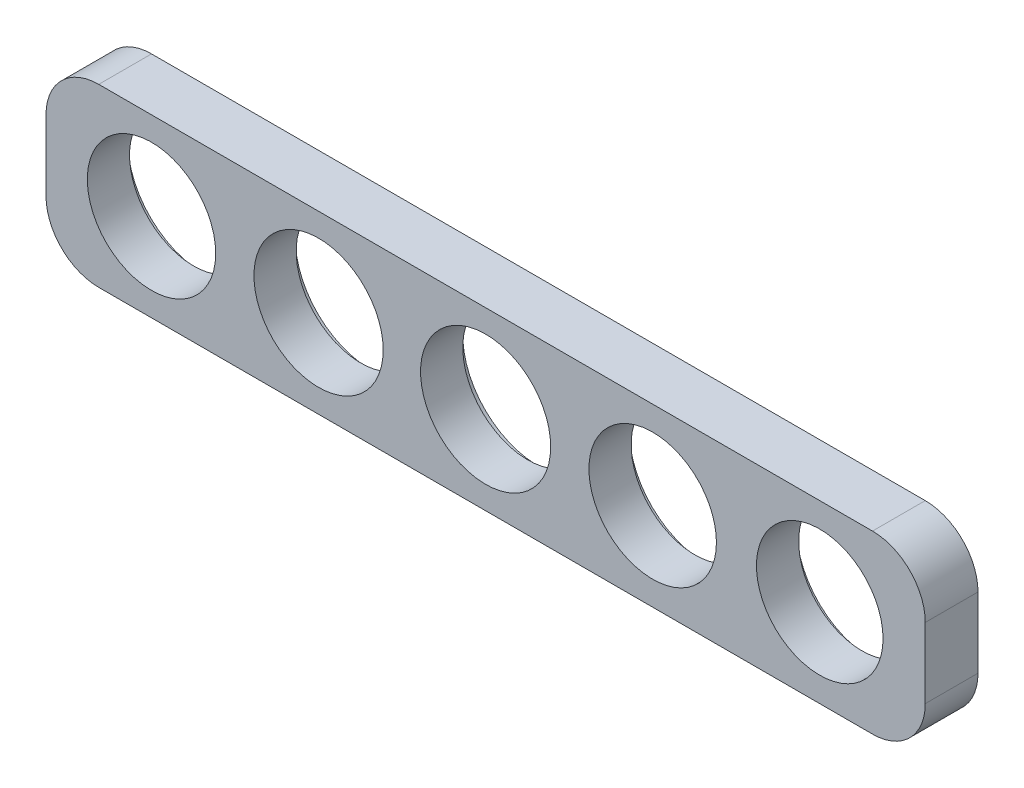
from build123d import *

# Parameters (mm, degrees)
SKETCH_1_W          = 50
SKETCH_1_H          = 10
EXTRUDE_1_DEPTH     = 3
SKETCH_1_3_R        = 3.65
SKETCH_1_3_R_2      = 3.675
SKETCH_1_3_R_3      = 3.7
SKETCH_1_3_R_4      = 3.625
SKETCH_1_3_R_5      = 3.6
CUT_EXTRUDE_1_DEPTH = 52.078371156
SKETCH_1_4_R        = 4.35
SKETCH_1_4_R_2      = 3.65
SKETCH_1_4_R_3      = 4.325
SKETCH_1_4_R_4      = 3.675
SKETCH_1_4_R_5      = 4.3
SKETCH_1_4_R_6      = 3.7
SKETCH_1_4_R_7      = 3.625
SKETCH_1_4_R_8      = 3.6
CUT_EXTRUDE_2_DEPTH = 0.6
FILLET_4_R          = 3


with BuildPart() as part:
    # 草图1 → 凸台-拉伸1 (new body)
    with BuildSketch(Plane.XY):
        with Locations((-25, 5)):
            Rectangle(SKETCH_1_W, SKETCH_1_H)
    extrude(amount=EXTRUDE_1_DEPTH)

    # 草图1<3> → 切除-拉伸1 (cut, through all)
    with BuildSketch(Plane.XY):
        with Locations((-44, 5)):
            Circle(SKETCH_1_3_R)
        with Locations((-34.5, 5)):
            Circle(SKETCH_1_3_R_2)
        with Locations((-25, 5)):
            Circle(SKETCH_1_3_R_3)
        with Locations((-15.5, 5)):
            Circle(SKETCH_1_3_R_4)
        with Locations((-6, 5)):
            Circle(SKETCH_1_3_R_5)
    extrude(amount=CUT_EXTRUDE_1_DEPTH, mode=Mode.SUBTRACT)

    # 草图1<4> → 切除-拉伸2 (cut)
    # profile 1 of 5: a face of its own
    with BuildSketch(Plane.XY):
        with Locations((-44, 5)):
            Circle(SKETCH_1_4_R)
        with Locations((-44, 5)):
            Circle(SKETCH_1_4_R_2, mode=Mode.SUBTRACT)
    # profile 2 of 5: a face of its own
    with BuildSketch(Plane.XY):
        with Locations((-34.5, 5)):
            Circle(SKETCH_1_4_R_3)
        with Locations((-34.5, 5)):
            Circle(SKETCH_1_4_R_4, mode=Mode.SUBTRACT)
    # profile 3 of 5: a face of its own
    with BuildSketch(Plane.XY):
        with Locations((-25, 5)):
            Circle(SKETCH_1_4_R_5)
        with Locations((-25, 5)):
            Circle(SKETCH_1_4_R_6, mode=Mode.SUBTRACT)
    # profile 4 of 5: a face of its own
    with BuildSketch(Plane.XY):
        with Locations((-15.5, 5)):
            Circle(SKETCH_1_4_R_3)
        with Locations((-15.5, 5)):
            Circle(SKETCH_1_4_R_7, mode=Mode.SUBTRACT)
    # profile 5 of 5: a face of its own
    with BuildSketch(Plane.XY):
        with Locations((-6, 5)):
            Circle(SKETCH_1_4_R_3)
        with Locations((-6, 5)):
            Circle(SKETCH_1_4_R_8, mode=Mode.SUBTRACT)
    extrude(amount=CUT_EXTRUDE_2_DEPTH, mode=Mode.SUBTRACT)

    # 圆角4
    fillet_4_edges = [part.edges().sort_by_distance(p)[0] for p in [
        (-50, 10, 1.5),
        (-50, 0, 1.5),
        (0, 10, 1.5),
        (0, 0, 1.5),
    ]]
    fillet(fillet_4_edges, radius=FILLET_4_R)


solid = part.part
